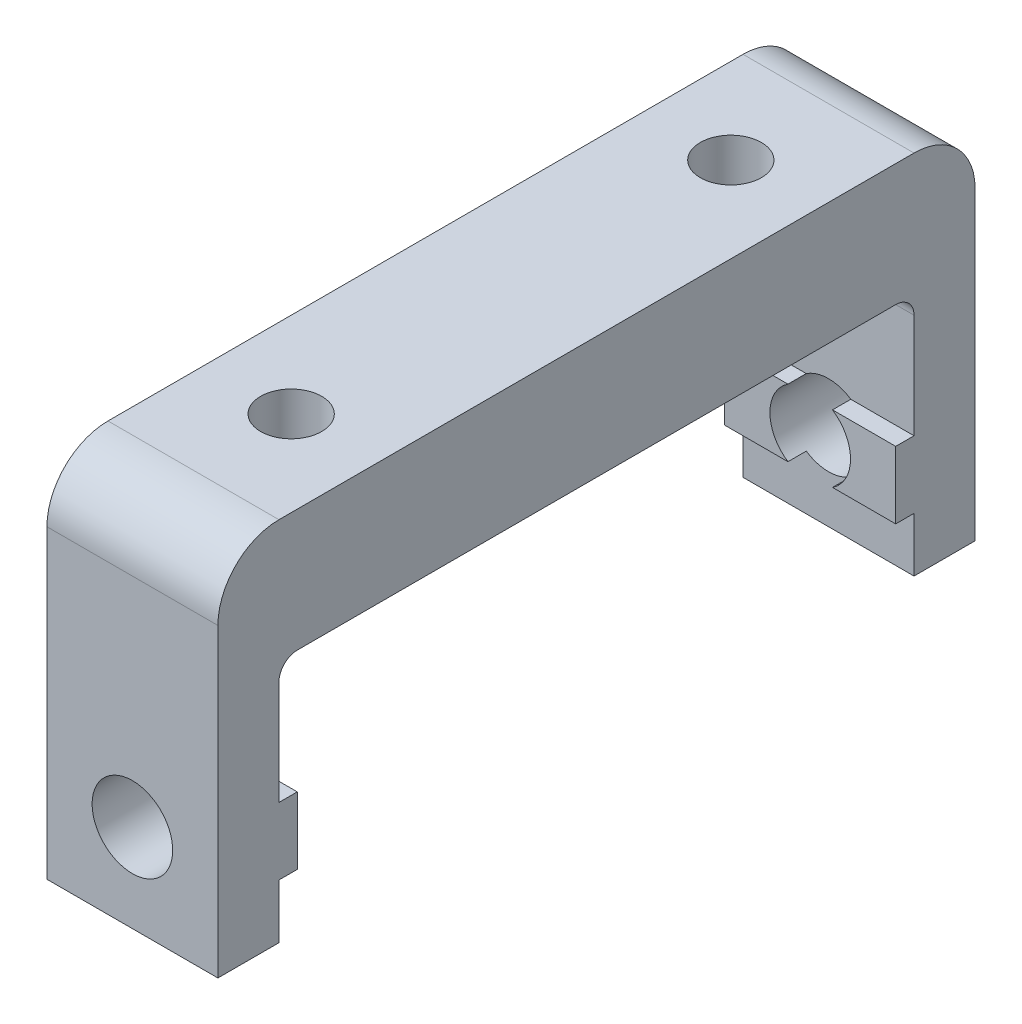
from build123d import *

# Parameters (mm, degrees)
BOSS_EXTRUDE1_DEPTH  = 14
SKETCH4_W            = 14
SKETCH4_H            = 5.5
BOSS_EXTRUDE3_DEPTH  = 1.5
CUT_EXTRUDE1_START   = -6.5
SKETCH2_R            = 3.3
CUT_EXTRUDE1_DEPTH   = 6.5
FILLET1_R            = 5
FILLET2_R            = 1.5
SKETCH7_R            = 2.5
CUT_EXTRUDE4_DEPTH   = 11
SKETCH7_3_R          = 4.5
SKETCH7_3_R_2        = 2.5
CUT_EXTRUDE5_DEPTH   = 4.6
FILLET1_OF_MIRROR1_R = 5
FILLET2_OF_MIRROR1_R = 1.5


with BuildPart() as part:
    # Sketch1 → Boss-Extrude1 (new body)
    with BuildSketch(Plane(origin=(0, 0, 0), x_dir=(0, 0, -1), z_dir=(1, 0, 0))):
        Polygon((0, 0), (-31, 0), (-31, -30), (-26, -30), (-26, -10), (0, -10), align=None)
    boss_extrude1 = extrude(amount=BOSS_EXTRUDE1_DEPTH)

    # Sketch4 → Boss-Extrude3 (add)
    with BuildSketch(Plane(origin=(0, 0, 26), x_dir=(-1, 0, 0), z_dir=(0, 0, -1))):
        with Locations((-7, -22.8)):
            Rectangle(SKETCH4_W, SKETCH4_H)
    boss_extrude3 = extrude(amount=BOSS_EXTRUDE3_DEPTH)

    # Sketch2 → Cut-Extrude1 (cut)
    with BuildSketch(Plane.XY.offset(31).offset(CUT_EXTRUDE1_START)):
        with Locations((7, -22.8)):
            Circle(SKETCH2_R)
    cut_extrude1 = extrude(amount=CUT_EXTRUDE1_DEPTH, mode=Mode.SUBTRACT)

    # Fillet1
    fillet1_edges = [part.edges().sort_by_distance(p)[0] for p in [
        (7, 0, 31),
    ]]
    fillet(fillet1_edges, radius=FILLET1_R)

    # Fillet2
    fillet2_edges = [part.edges().sort_by_distance(p)[0] for p in [
        (7, -10, 26),
    ]]
    fillet(fillet2_edges, radius=FILLET2_R)

    # Sketch7 → Cut-Extrude4 (cut, through all)
    with BuildSketch(Plane(origin=(0, -10, 0), x_dir=(1, 0, 0), z_dir=(0, 1, 0))):
        with Locations((7, -18)):
            Circle(SKETCH7_R)
    cut_extrude4 = extrude(amount=CUT_EXTRUDE4_DEPTH, mode=Mode.SUBTRACT)

    # Sketch7_3 → Cut-Extrude5 (cut)
    with BuildSketch(Plane(origin=(0, -10, 0), x_dir=(1, 0, 0), z_dir=(0, 1, 0))):
        with Locations((7, -18)):
            Circle(SKETCH7_3_R)
        with Locations((7, -18)):
            Circle(SKETCH7_3_R_2, mode=Mode.SUBTRACT)
    cut_extrude5 = extrude(amount=CUT_EXTRUDE5_DEPTH, mode=Mode.SUBTRACT)

    # Mirror1: Boss-Extrude1, Boss-Extrude3, Cut-Extrude1, Cut-Extrude4, Cut-Extrude5 across plane
    add(boss_extrude1.mirror(Plane.XY))
    add(boss_extrude3.mirror(Plane.XY))
    add(cut_extrude1.mirror(Plane.XY), mode=Mode.SUBTRACT)
    add(cut_extrude4.mirror(Plane.XY), mode=Mode.SUBTRACT)
    add(cut_extrude5.mirror(Plane.XY), mode=Mode.SUBTRACT)

    # Fillet1 of Mirror1
    fillet1_of_mirror1_edges = [part.edges().sort_by_distance(p)[0] for p in [
        (7, 0, -31),
    ]]
    fillet(fillet1_of_mirror1_edges, radius=FILLET1_OF_MIRROR1_R)

    # Fillet2 of Mirror1
    fillet2_of_mirror1_edges = [part.edges().sort_by_distance(p)[0] for p in [
        (7, -10, -26),
    ]]
    fillet(fillet2_of_mirror1_edges, radius=FILLET2_OF_MIRROR1_R)


solid = part.part
